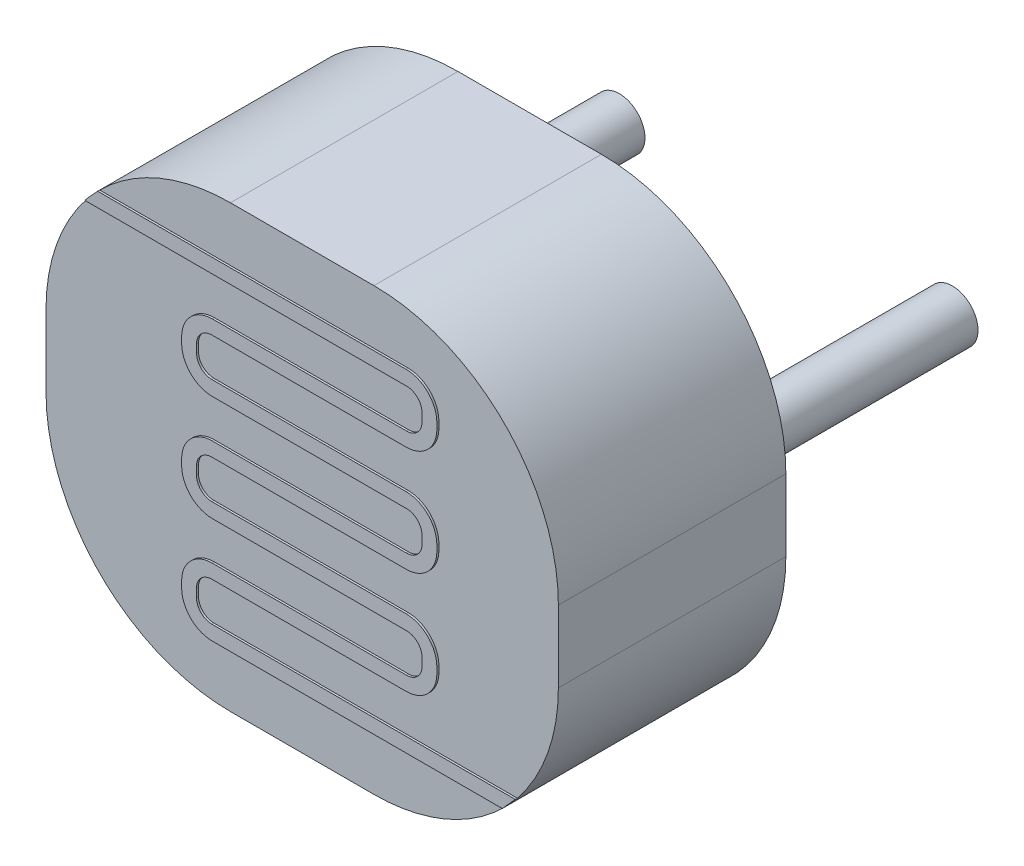
from build123d import *

# Parameters (mm, degrees)
EXTRUDE1_DEPTH = 2.22
EXTRUDE6_DEPTH = 0.02
SKETCH2_R      = 0.25
EXTRUDE7_DEPTH = 2.5


with BuildPart() as part:
    # Sketch1 → Extrude1 (new body)
    with BuildSketch(Plane.XY):
        with BuildLine():
            Line((-6.39861095, 5.506998303), (-4.99861095, 5.506998303))
            ThreePointArc((-4.99861095, 5.506998303), (-3.725818744, 4.979790509), (-3.19861095, 3.706998303))
            Line((-3.19861095, 3.706998303), (-3.19861095, 3.006998303))
            ThreePointArc((-3.19861095, 3.006998303), (-3.725818744, 1.734206097), (-4.99861095, 1.206998303))
            Line((-4.99861095, 1.206998303), (-6.39861095, 1.206998303))
            ThreePointArc((-6.39861095, 1.206998303), (-7.671403156, 1.734206097), (-8.19861095, 3.006998303))
            Line((-8.19861095, 3.006998303), (-8.19861095, 3.706998303))
            ThreePointArc((-8.19861095, 3.706998303), (-7.671403156, 4.979790509), (-6.39861095, 5.506998303))
        make_face()
    extrude(amount=EXTRUDE1_DEPTH)

    # Sketch3 → Extrude6 (add)
    with BuildSketch(Plane.XY.offset(2.22)):
        with BuildLine():
            Line((-4.659129836, 4.836998303), (-7.799717656, 4.836998303))
            Line((-7.799717656, 4.836998303), (-7.757450007, 4.887488208))
            Line((-7.757450007, 4.887488208), (-7.674189251, 4.976998303))
            Line((-7.674189251, 4.976998303), (-4.664395148, 4.976998303))
            ThreePointArc((-4.664395148, 4.976998303), (-4.452263114, 4.889130337), (-4.364395148, 4.676998303))
            Line((-4.364395148, 4.676998303), (-4.364395148, 4.619148396))
            ThreePointArc((-4.364395148, 4.619148396), (-4.452263114, 4.407016361), (-4.664395148, 4.319148396))
            Line((-4.664395148, 4.319148396), (-6.560237828, 4.319148396))
            ThreePointArc((-6.560237828, 4.319148396), (-6.666303845, 4.275214413), (-6.710237828, 4.169148396))
            Line((-6.710237828, 4.169148396), (-6.710237828, 4.093148396))
            ThreePointArc((-6.710237828, 4.093148396), (-6.666303845, 3.987082379), (-6.560237828, 3.943148396))
            Line((-6.560237828, 3.943148396), (-4.664395148, 3.943148396))
            ThreePointArc((-4.664395148, 3.943148396), (-4.452263114, 3.85528043), (-4.364395148, 3.643148396))
            Line((-4.364395148, 3.643148396), (-4.364395148, 3.587148396))
            ThreePointArc((-4.364395148, 3.587148396), (-4.452263114, 3.375016361), (-4.664395148, 3.287148396))
            Line((-4.664395148, 3.287148396), (-6.560237828, 3.287148396))
            ThreePointArc((-6.560237828, 3.287148396), (-6.666303845, 3.243214413), (-6.710237828, 3.137148396))
            Line((-6.710237828, 3.137148396), (-6.710237828, 3.061148396))
            ThreePointArc((-6.710237828, 3.061148396), (-6.666303845, 2.955082379), (-6.560237828, 2.911148396))
            Line((-6.560237828, 2.911148396), (-4.664395148, 2.911148396))
            ThreePointArc((-4.664395148, 2.911148396), (-4.452263114, 2.82328043), (-4.364395148, 2.611148396))
            Line((-4.364395148, 2.611148396), (-4.364395148, 2.555148396))
            ThreePointArc((-4.364395148, 2.555148396), (-4.452263114, 2.343016361), (-4.664395148, 2.255148396))
            Line((-4.664395148, 2.255148396), (-6.560237828, 2.255148396))
            ThreePointArc((-6.560237828, 2.255148396), (-6.666303845, 2.211214413), (-6.710237828, 2.105148396))
            Line((-6.710237828, 2.105148396), (-6.710237828, 2.024997149))
            ThreePointArc((-6.710237828, 2.024997149), (-6.666303845, 1.918931132), (-6.560237828, 1.874997149))
            Line((-6.560237828, 1.874997149), (-3.599120547, 1.874997149))
            Line((-3.599120547, 1.874997149), (-3.725818744, 1.734206097))
            Line((-3.725818744, 1.734206097), (-6.554972516, 1.734206097))
            ThreePointArc((-6.554972516, 1.734206097), (-6.767104551, 1.822074063), (-6.854972516, 2.034206097))
            Line((-6.854972516, 2.034206097), (-6.854972516, 2.093703593))
            ThreePointArc((-6.854972516, 2.093703593), (-6.767104551, 2.305835627), (-6.554972516, 2.393703593))
            Line((-6.554972516, 2.393703593), (-4.659129836, 2.393703593))
            ThreePointArc((-4.659129836, 2.393703593), (-4.553063819, 2.437637576), (-4.509129836, 2.543703593))
            Line((-4.509129836, 2.543703593), (-4.509129836, 2.619703593))
            ThreePointArc((-4.509129836, 2.619703593), (-4.553063819, 2.72576961), (-4.659129836, 2.769703593))
            Line((-4.659129836, 2.769703593), (-6.554972516, 2.769703593))
            ThreePointArc((-6.554972516, 2.769703593), (-6.767104551, 2.857571559), (-6.854972516, 3.069703593))
            Line((-6.854972516, 3.069703593), (-6.854972516, 3.125703593))
            ThreePointArc((-6.854972516, 3.125703593), (-6.767104551, 3.337835627), (-6.554972516, 3.425703593))
            Line((-6.554972516, 3.425703593), (-4.659129836, 3.425703593))
            ThreePointArc((-4.659129836, 3.425703593), (-4.553063819, 3.469637576), (-4.509129836, 3.575703593))
            Line((-4.509129836, 3.575703593), (-4.509129836, 3.651703593))
            ThreePointArc((-4.509129836, 3.651703593), (-4.553063819, 3.75776961), (-4.659129836, 3.801703593))
            Line((-4.659129836, 3.801703593), (-6.554972516, 3.801703593))
            ThreePointArc((-6.554972516, 3.801703593), (-6.767104551, 3.889571559), (-6.854972516, 4.101703593))
            Line((-6.854972516, 4.101703593), (-6.854972516, 4.157703593))
            ThreePointArc((-6.854972516, 4.157703593), (-6.767104551, 4.369835627), (-6.554972516, 4.457703593))
            Line((-6.554972516, 4.457703593), (-4.659129836, 4.457703593))
            ThreePointArc((-4.659129836, 4.457703593), (-4.553063819, 4.501637576), (-4.509129836, 4.607703593))
            Line((-4.509129836, 4.607703593), (-4.509129836, 4.686998303))
            ThreePointArc((-4.509129836, 4.686998303), (-4.553063819, 4.79306432), (-4.659129836, 4.836998303))
        make_face()
    extrude(amount=EXTRUDE6_DEPTH)

    # Sketch2 → Extrude7 (add)
    with BuildSketch(Plane(origin=(0, 0, 0), x_dir=(-1, 0, 0), z_dir=(0, 0, -1))):
        with Locations(Location((4.07361095, 3.356998303, 0), (0, 0, 180))):
            Circle(SKETCH2_R)
        with Locations(Location((7.32361095, 3.356998303, 0), (0, 0, 180))):
            Circle(SKETCH2_R)
    extrude(amount=EXTRUDE7_DEPTH)


solid = part.part
